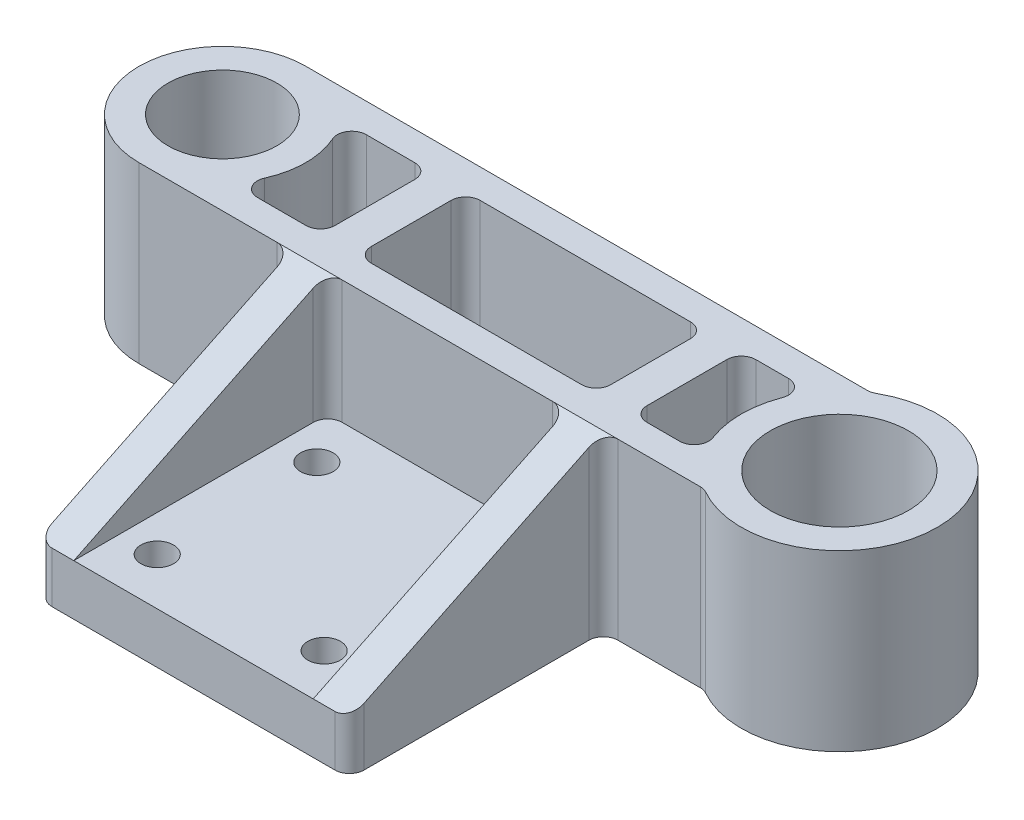
from build123d import *

# Parameters (mm, degrees)
SKETCH1_R               = 7.5
SKETCH1_R_2             = 9.525
BOSS_EXTRUDE1_DEPTH     = 24
SKETCH8_W               = 5
SKETCH8_H               = 17
BOSS_EXTRUDE4_DEPTH     = 35
CUT_EXTRUDE4_DEPTH      = 33.5125
CUT_EXTRUDE4_DEPTH_BACK = 52
SKETCH10_W              = 33
SKETCH10_H              = 15
CUT_EXTRUDE5_DEPTH      = 35
FILLET1_R               = 2
SKETCH12_R              = 2.25
CUT_EXTRUDE6_DEPTH      = 35


with BuildPart() as part:
    # Sketch1 → Boss-Extrude1 (new body)
    with BuildSketch(Plane(origin=(0, 0, 0), x_dir=(1, 0, 0), z_dir=(0, 1, 0))):
        with BuildLine():
            Line((35.393818591, 11.5), (-42.5125, 11.5))
            ThreePointArc((-42.5125, 11.5), (-54.0125, 0), (-42.5125, -11.5))
            Line((-42.5125, -11.5), (35.393818591, -11.5))
            ThreePointArc((35.393818591, -11.5), (56.0375, 0), (35.393818591, 11.5))
        make_face()
        with Locations((-42.5125, 0)):
            Circle(SKETCH1_R, mode=Mode.SUBTRACT)
        with Locations((42.5125, 0)):
            Circle(SKETCH1_R_2, mode=Mode.SUBTRACT)
    extrude(amount=BOSS_EXTRUDE1_DEPTH)

    # Sketch8 → Boss-Extrude4 (add)
    with BuildSketch(Plane.XY.offset(11.5)):
        with Locations((-19, 15.5)):
            Rectangle(SKETCH8_W, SKETCH8_H)
        Polygon((-16.5, 7), (-21.5, 7), (-21.5, 0), (21.5, 0), (21.5, 7), (16.5, 7), align=None)
        with Locations((19, 15.5)):
            Rectangle(SKETCH8_W, SKETCH8_H)
    extrude(amount=BOSS_EXTRUDE4_DEPTH)

    # Sketch9 → Cut-Extrude4 (cut, two sides)
    with BuildSketch(Plane.ZY.offset(21.5)) as cut_extrude4_sk:
        Polygon((11.5, 24), (46.5, 7), (46.5, 24), align=None)
    extrude(amount=CUT_EXTRUDE4_DEPTH, mode=Mode.SUBTRACT)
    extrude(cut_extrude4_sk.sketch, amount=-CUT_EXTRUDE4_DEPTH_BACK, mode=Mode.SUBTRACT)

    # Sketch10 → Cut-Extrude5 (cut)
    with BuildSketch(Plane(origin=(0, 24, 0), x_dir=(1, 0, 0), z_dir=(0, 1, 0))):
        with BuildLine():
            Line((-21.5, 7.5), (-33.794702113, 7.5))
            ThreePointArc((-33.794702113, 7.5), (-31.730462259, 3.999707758), (-31.0125, 0))
            ThreePointArc((-31.0125, 0), (-31.730462259, -3.999707758), (-33.794702113, -7.5))
            Line((-33.794702113, -7.5), (-21.5, -7.5))
            Line((-21.5, -7.5), (-21.5, 7.5))
        make_face()
        Rectangle(SKETCH10_W, SKETCH10_H)
        with BuildLine():
            Line((31.257473345, 7.5), (21.5, 7.5))
            Line((21.5, 7.5), (21.5, -7.5))
            Line((21.5, -7.5), (31.257473345, -7.5))
            ThreePointArc((31.257473345, -7.5), (28.9875, 0), (31.257473345, 7.5))
        make_face()
    extrude(amount=-CUT_EXTRUDE5_DEPTH, mode=Mode.SUBTRACT)

    # Fillet1
    fillet1_edges = [part.edges().sort_by_distance(p)[0] for p in [
        (-16.5, 12, -7.5),
        (16.5, 12, -7.5),
        (31.257473345, 12, -7.5),
        (31.257473345, 12, 7.5),
        (21.5, 12, 7.5),
        (35.393818591, 12, 11.5),
        (21.5, 12, -7.5),
        (35.393818591, 12, -11.5),
        (-21.5, 3.5, 46.5),
        (-16.5, 15.5, 11.5),
        (-21.5, 12, 11.5),
        (16.5, 15.5, 11.5),
        (21.5, 12, 11.5),
        (21.5, 3.5, 46.5),
        (-33.794702113, 12, 7.5),
        (-33.794702113, 12, -7.5),
        (-21.5, 12, -7.5),
        (-21.5, 12, 7.5),
        (16.5, 12, 7.5),
        (-16.5, 12, 7.5),
    ]]
    fillet(fillet1_edges, radius=FILLET1_R)

    # Sketch12 → Cut-Extrude6 (cut)
    with BuildSketch(Plane.XZ):
        with Locations((-11.5, 40)):
            Circle(SKETCH12_R)
        with Locations((-11.5, 18)):
            Circle(SKETCH12_R)
        with Locations((11.5, 40)):
            Circle(SKETCH12_R)
        with Locations((11.5, 18)):
            Circle(SKETCH12_R)
    extrude(amount=-CUT_EXTRUDE6_DEPTH, mode=Mode.SUBTRACT)


solid = part.part
